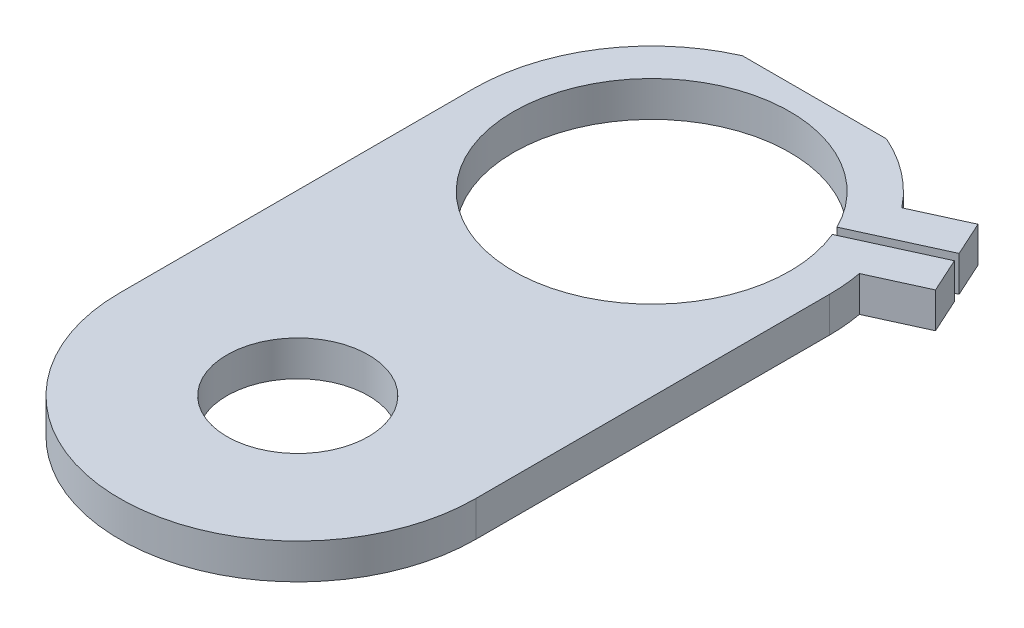
from build123d import *

# Parameters (mm, degrees)
SKETCH1_R           = 25.4
BOSS_EXTRUDE5_DEPTH = 12.7
SKETCH4_9_R         = 49.587536422
CUT_EXTRUDE9_DEPTH  = 12.7
SKETCH4_10_R        = 3.175
CUT_EXTRUDE10_DEPTH = 6.35


with BuildPart() as part:
    # Sketch1 → Boss-Extrude5 (new body)
    with BuildSketch(Plane(origin=(0, 0, 0), x_dir=(1, 0, 0), z_dir=(0, 1, 0))):
        with BuildLine():
            Line((63.881, 0), (63.881, -127))
            ThreePointArc((63.881, -127), (0, -190.881), (-63.881, -127))
            Line((-63.881, -127), (-63.881, 0))
            ThreePointArc((-63.881, 0), (-53.533587031, 34.855949573), (-25.843485852, 58.42))
            Line((-25.843485852, 58.42), (0, 58.42))
            Line((0, 58.42), (25.843485852, 58.42))
            ThreePointArc((25.843485852, 58.42), (39.052759066, 50.553577226), (50.000033281, 39.759009455))
            Line((50.000033281, 39.759009455), (68.760605235, 48.322238074))
            Line((68.760605235, 48.322238074), (74.445380321, 35.867866389))
            Line((74.445380321, 35.867866389), (43.162005956, 21.588627605))
            ThreePointArc((43.162005956, 21.588627605), (-43.902763298, -20.039335689), (44.587930732, 18.464669861))
            Line((44.587930732, 18.464669861), (75.871305097, 32.743908644))
            Line((75.871305097, 32.743908644), (81.556080183, 20.289536959))
            Line((81.556080183, 20.289536959), (62.795508229, 11.726308341))
            ThreePointArc((62.795508229, 11.726308341), (63.609048186, 5.888221287), (63.881, 0))
        make_face()
        with Locations((0, -127)):
            Circle(SKETCH1_R, mode=Mode.SUBTRACT)
    extrude(amount=BOSS_EXTRUDE5_DEPTH)

    # Sketch4_9 → Cut-Extrude9 (cut)
    with BuildSketch(Plane(origin=(0, 0, 0), x_dir=(1, 0, 0), z_dir=(0, 1, 0))):
        Circle(SKETCH4_9_R)
    extrude(amount=CUT_EXTRUDE9_DEPTH, mode=Mode.SUBTRACT)

    # Sketch4_10 → Cut-Extrude10 (cut)
    with BuildSketch(Plane(origin=(0, 0, 0), x_dir=(1, 0, 0), z_dir=(0, 1, 0))):
        with Locations((0, -171.45)):
            Circle(SKETCH4_10_R)
        with Locations((-44.45, -127)):
            Circle(SKETCH4_10_R)
        with Locations((44.45, -127)):
            Circle(SKETCH4_10_R)
        with Locations((0, -82.55)):
            Circle(SKETCH4_10_R)
        with Locations((-44.45, -41.311332975)):
            Circle(SKETCH4_10_R)
        with Locations((44.45, -45.306446958)):
            Circle(SKETCH4_10_R)
    extrude(amount=CUT_EXTRUDE10_DEPTH, mode=Mode.SUBTRACT)


solid = part.part
